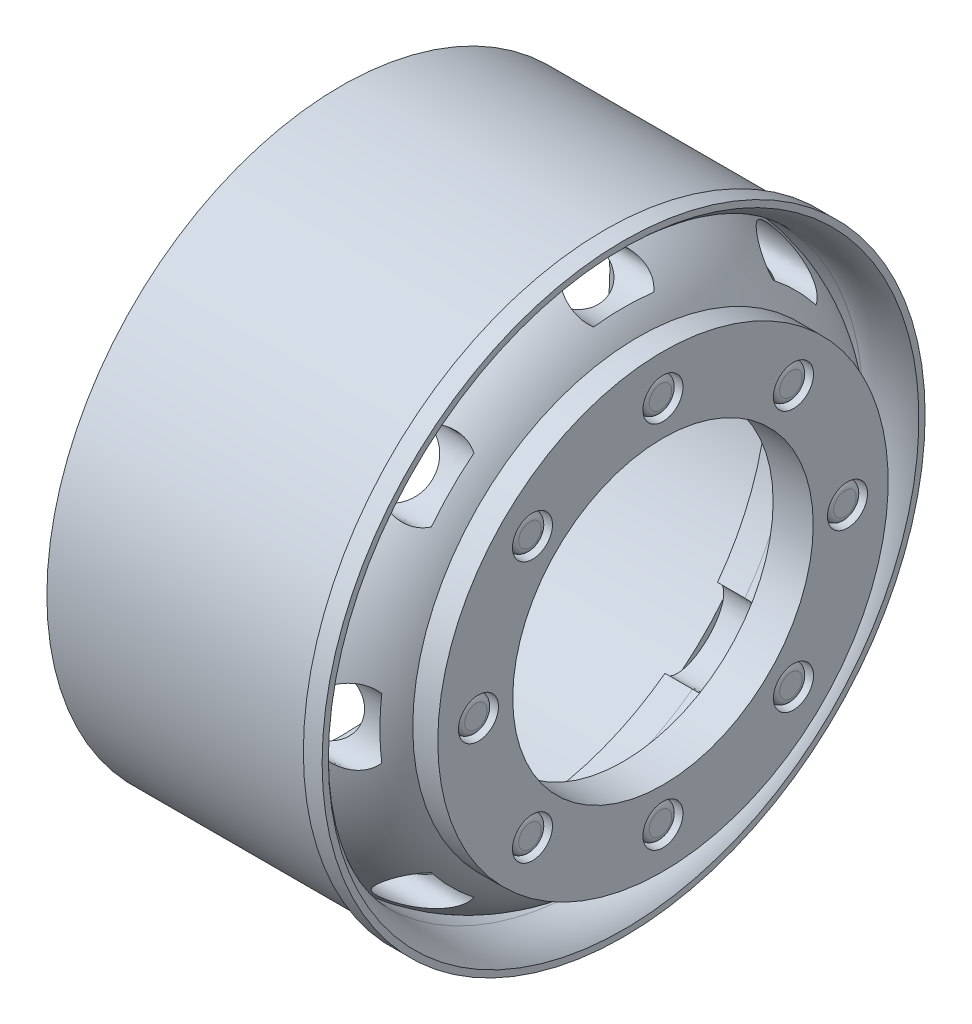
from build123d import *

# Parameters (mm, degrees)
SKETCH3_RX          = 3
SKETCH3_RY          = 1.666666667
CUT_EXTRUDE2_DEPTH  = 8.793413
CIRPATTERN1_COUNT   = 8
SKETCH5_R           = 1.6
CUT_EXTRUDE3_DEPTH  = 1.703824
SKETCH6_R           = 1.4
BOSS_EXTRUDE1_DEPTH = 1.5
FILLET1_R           = 0.5
SKETCH7_R           = 12.008791447
CUT_EXTRUDE4_DEPTH  = 26.745811191


with BuildPart() as part:
    # Sketch1 → Revolve1 (revolve)
    with BuildSketch(Plane.XY):
        with BuildLine():
            Line((-10, 23.5), (11.1, 23.5))
            Line((11.1, 23.5), (11.1, 24.1))
            Line((11.1, 24.1), (12.6, 24.1))
            Line((12.6, 24.1), (12.6, 23.6))
            ThreePointArc((12.6, 23.6), (11.157412974, 22.597075431), (9.425748686, 22.3))
            Line((9.425748686, 22.3), (6, 22.3))
            ThreePointArc((6, 22.3), (10.429661133, 21.152912389), (13.745811191, 18))
            Line((13.745811191, 18), (15.745811191, 18))
            Line((15.745811191, 18), (15.745811191, 8.483712034))
            Line((15.745811191, 8.483712034), (12.541986778, 8.483712034))
            Line((12.541986778, 8.483712034), (12.541986778, 16))
            ThreePointArc((12.541986778, 16), (9.914319577, 19.128751492), (6, 20.3))
            Line((6, 20.3), (3.806587083, 20.3))
            Line((3.806587083, 20.3), (3.806587083, 21.5))
            Line((3.806587083, 21.5), (-10, 21.5))
            Line((-10, 21.5), (-10, 23.5))
        make_face()
    revolve(axis=Axis((-25, 0, 0), (1, 0, 0)))

    # Sketch3 → Cut-Extrude2 (cut)
    with BuildSketch(Plane(origin=(12.6, 0, 0), x_dir=(0, 0, -1), z_dir=(1, 0, 0))):
        with Locations((0, 20.323082194)):
            Ellipse(SKETCH3_RX, SKETCH3_RY)
    cut_extrude2 = extrude(amount=-CUT_EXTRUDE2_DEPTH, mode=Mode.SUBTRACT)

    # CirPattern1: Cut-Extrude2 ×8 about axis
    cirpattern1_axis = Axis((15.745811191, 0, 0), (-1, 0, 0))
    for i in range(1, CIRPATTERN1_COUNT):
        add(cut_extrude2.rotate(cirpattern1_axis, i * 360 / CIRPATTERN1_COUNT), mode=Mode.SUBTRACT)

    # Sketch5 → Cut-Extrude3 (cut)
    with BuildSketch(Plane(origin=(15.745811191, 0, 0), x_dir=(0, 0, -1), z_dir=(1, 0, 0))):
        with Locations((0, 14.75)):
            Circle(SKETCH5_R)
        with Locations((10.429825023, 10.429825023)):
            Circle(SKETCH5_R)
        with Locations((14.75, 0)):
            Circle(SKETCH5_R)
        with Locations((10.429825023, -10.429825023)):
            Circle(SKETCH5_R)
        with Locations((0, -14.75)):
            Circle(SKETCH5_R)
        with Locations((-10.429825023, -10.429825023)):
            Circle(SKETCH5_R)
        with Locations((-14.75, 0)):
            Circle(SKETCH5_R)
        with Locations((-10.429825023, 10.429825023)):
            Circle(SKETCH5_R)
    extrude(amount=-CUT_EXTRUDE3_DEPTH, mode=Mode.SUBTRACT)

    # Sketch6 → Boss-Extrude1 (add)
    with BuildSketch(Plane(origin=(14.041986778, 0, 0), x_dir=(0, 0, -1), z_dir=(1, 0, 0))):
        with Locations((-14.75, 0)):
            Circle(SKETCH6_R)
        with Locations((-10.429825023, 10.429825023)):
            Circle(SKETCH6_R)
        with Locations((0, 14.75)):
            Circle(SKETCH6_R)
        with Locations((10.429825023, 10.429825023)):
            Circle(SKETCH6_R)
        with Locations((14.75, 0)):
            Circle(SKETCH6_R)
        with Locations((10.429825023, -10.429825023)):
            Circle(SKETCH6_R)
        with Locations((0, -14.75)):
            Circle(SKETCH6_R)
        with Locations((-10.429825023, -10.429825023)):
            Circle(SKETCH6_R)
    extrude(amount=BOSS_EXTRUDE1_DEPTH)

    # Fillet1
    fillet1_edges = [part.edges().sort_by_distance(p)[0] for p in [
        (15.541986778, 0, 16.15),
        (15.541986778, 10.429825023, 11.829825023),
        (15.541986778, 14.75, 1.4),
        (15.541986778, 10.429825023, -9.029825023),
        (15.541986778, 0, -13.35),
        (15.541986778, -10.429825023, -9.029825023),
        (15.541986778, -14.75, 1.4),
        (15.541986778, -10.429825023, 11.829825023),
    ]]
    fillet(fillet1_edges, radius=FILLET1_R)

    # Sketch7 → Cut-Extrude4 (cut, through all)
    with BuildSketch(Plane(origin=(15.745811191, 0, 0), x_dir=(0, 0, -1), z_dir=(1, 0, 0))):
        Circle(SKETCH7_R)
    extrude(amount=-CUT_EXTRUDE4_DEPTH, mode=Mode.SUBTRACT)


solid = part.part
